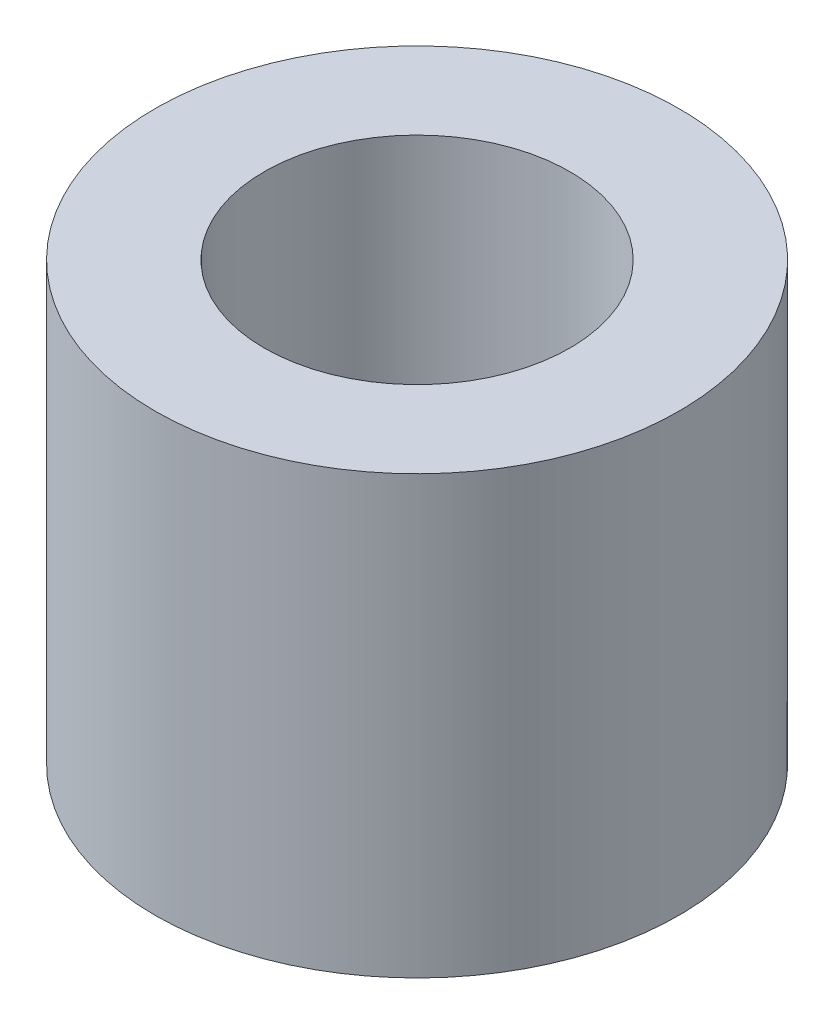
from build123d import *

# Parameters (mm, degrees)
SKETCH1_R           = 3
SKETCH1_R_2         = 1.75
BOSS_EXTRUDE1_DEPTH = 5


with BuildPart() as part:
    # Sketch1 → Boss-Extrude1 (new body)
    with BuildSketch(Plane(origin=(0, 0, 0), x_dir=(1, 0, 0), z_dir=(0, 1, 0))):
        Circle(SKETCH1_R)
        Circle(SKETCH1_R_2, mode=Mode.SUBTRACT)
    extrude(amount=BOSS_EXTRUDE1_DEPTH)


solid = part.part
